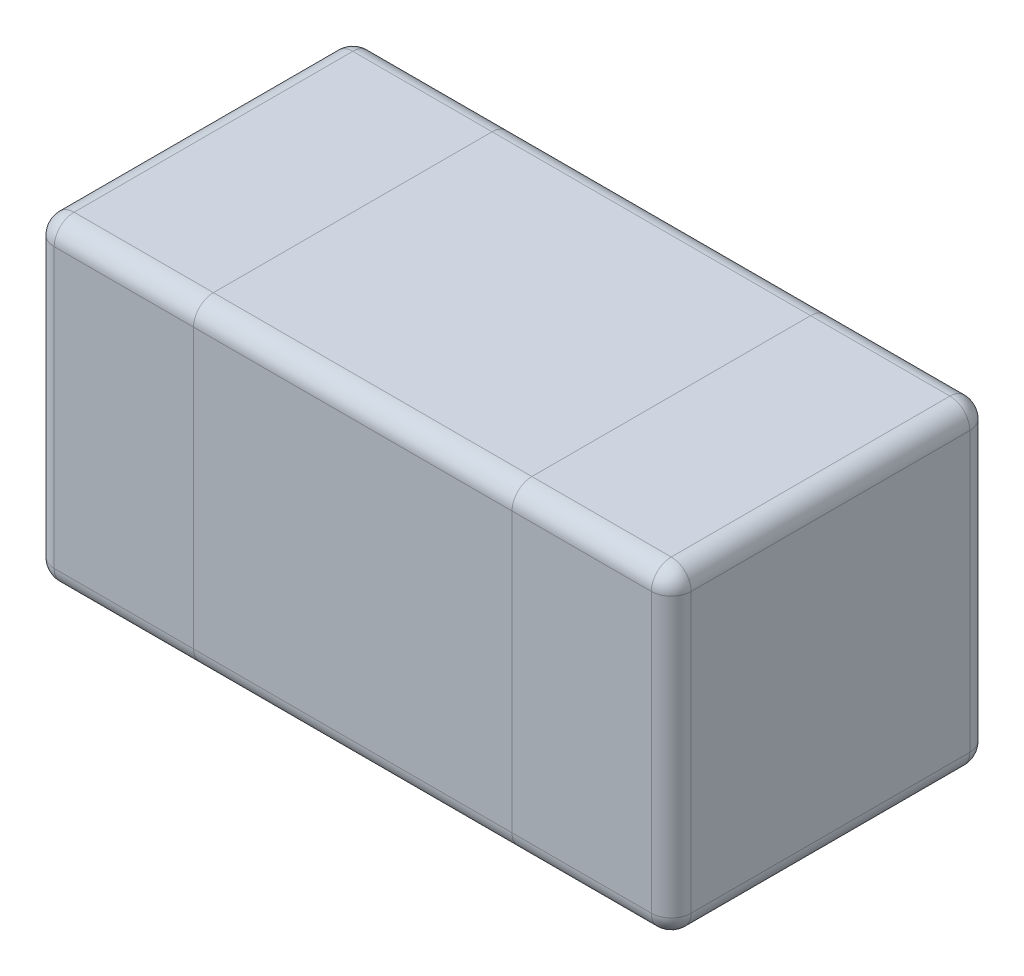
from build123d import *

# Parameters (mm, degrees)
SKETCH3_W             = 0.4
SKETCH3_H             = 0.8
BOSS_EXTRUDE2_DEPTH   = 0.8
BOSS_EXTRUDE2_2_DEPTH = 0.8
SKETCH4_W             = 0.8
SKETCH4_H             = 0.8
BOSS_EXTRUDE3_DEPTH   = 0.8
FILLET1_R             = 0.05
FILLET2_R             = 0.05
FILLET3_R             = 0.05


with BuildPart() as part:
    # Sketch3 → Boss-Extrude2 (new body)
    with BuildSketch(Plane(origin=(0, 0, 0), x_dir=(1, 0, 0), z_dir=(0, 1, 0))):
        with Locations((0.2, 0.4)):
            Rectangle(SKETCH3_W, SKETCH3_H)
    extrude(amount=BOSS_EXTRUDE2_DEPTH)

    # Fillet1
    fillet1_edges = [part.edges().sort_by_distance(p)[0] for p in [
        (0.2, 0.8, -0.8),
        (0, 0.8, -0.4),
        (0.2, 0, -0.8),
        (0.2, 0, 0),
        (0, 0, -0.4),
        (0.2, 0.8, 0),
        (0, 0.4, -0.8),
        (0, 0.4, 0),
    ]]
    fillet(fillet1_edges, radius=FILLET1_R)


with BuildPart() as body_2:
    # Sketch3 → Boss-Extrude2 2 (new body)
    with BuildSketch(Plane(origin=(0, 0, 0), x_dir=(1, 0, 0), z_dir=(0, 1, 0))):
        with Locations((1.4, 0.4)):
            Rectangle(SKETCH3_W, SKETCH3_H)
    extrude(amount=BOSS_EXTRUDE2_2_DEPTH)

    # Fillet2
    fillet2_edges = [body_2.edges().sort_by_distance(p)[0] for p in [
        (1.6, 0.8, -0.4),
        (1.4, 0.8, -0.8),
        (1.4, 0, -0.8),
        (1.6, 0, -0.4),
        (1.4, 0, 0),
        (1.4, 0.8, 0),
        (1.6, 0.4, -0.8),
        (1.6, 0.4, 0),
    ]]
    fillet(fillet2_edges, radius=FILLET2_R)


with BuildPart() as body_3:
    # Sketch4 → Boss-Extrude3 (new body)
    with BuildSketch(Plane(origin=(0, 0, 0), x_dir=(-1, 0, 0), z_dir=(0, -1, 0))):
        with Locations((-0.8, 0.4)):
            Rectangle(SKETCH4_W, SKETCH4_H)
    extrude(amount=-BOSS_EXTRUDE3_DEPTH)

    # Fillet3
    fillet3_edges = [body_3.edges().sort_by_distance(p)[0] for p in [
        (0.8, 0.8, 0),
        (0.8, 0, 0),
        (0.8, 0, -0.8),
        (0.8, 0.8, -0.8),
    ]]
    fillet(fillet3_edges, radius=FILLET3_R)


solid = Compound([part.part, body_2.part, body_3.part])
